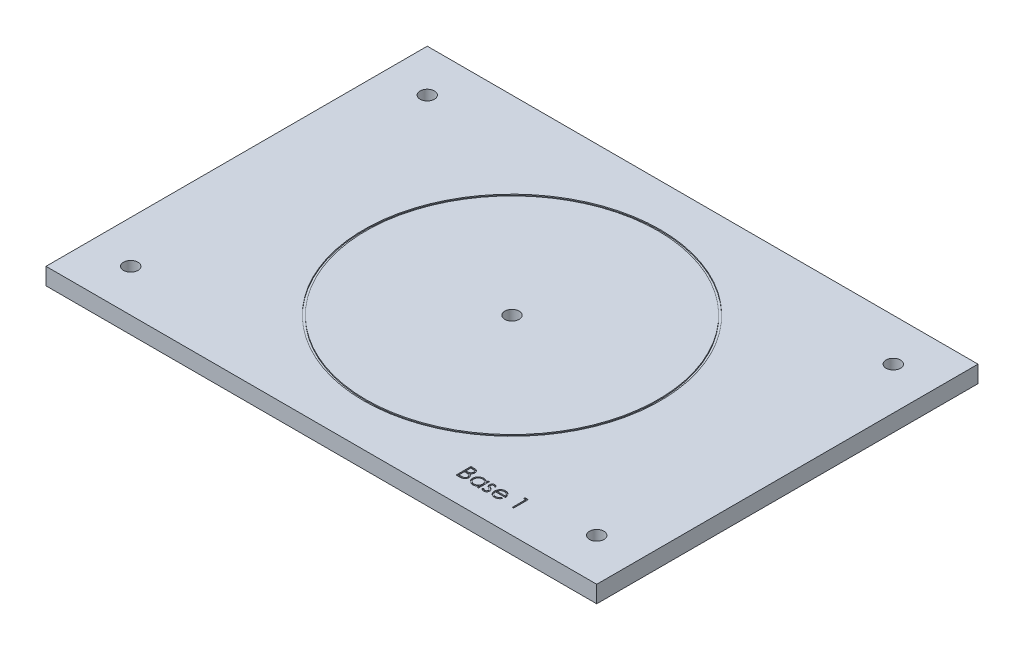
from build123d import *

# Parameters (mm, degrees)
CROQUIS1_W                       = 130
CROQUIS1_H                       = 90
SALIENTE_EXTRUIR1_DEPTH          = 2
TALADRO_DE_MARGEN_PARA_M31_D     = 3.4
TALADRO_DE_MARGEN_PARA_M31_DEPTH = 40
TALADRO_DE_MARGEN_PARA_M31_TIP   = 1.021463052
CORTAR_EXTRUIR1_DEPTH            = 0.25
CROQUIS5_R                       = 35
CROQUIS5_R_2                     = 34.5
CORTAR_EXTRUIR2_DEPTH            = 0.25
TALADRO_DE_MARGEN_PARA_M32_D     = 3.4


with BuildPart() as part:
    # Croquis1 → Saliente-Extruir1 (new, symmetric)
    with BuildSketch(Plane(origin=(0, 0, 0), x_dir=(1, 0, 0), z_dir=(0, 1, 0))):
        Rectangle(CROQUIS1_W, CROQUIS1_H)
    extrude(amount=SALIENTE_EXTRUIR1_DEPTH, both=True)

    # Taladro de margen para M31
    with Locations(Plane(origin=(0, 2, 0), x_dir=(1, 0, 0), z_dir=(0, 1, 0))):
        with Locations((-55, 35), (55, 35), (55, -35), (-55, -35)):
            Hole(TALADRO_DE_MARGEN_PARA_M31_D / 2, depth=TALADRO_DE_MARGEN_PARA_M31_DEPTH)
            with Locations((0, 0, -(TALADRO_DE_MARGEN_PARA_M31_DEPTH + TALADRO_DE_MARGEN_PARA_M31_TIP / 2))):  # 118° drill point
                Cone(0, TALADRO_DE_MARGEN_PARA_M31_D / 2, TALADRO_DE_MARGEN_PARA_M31_TIP, mode=Mode.SUBTRACT)

    # Croquis4 → Cortar-Extruir1 (cut)
    with BuildSketch(Plane(origin=(0, 2, 0), x_dir=(1, 0, 0), z_dir=(0, 1, 0))):
        with BuildLine():
            Line((26.072765662, -35.764073187), (26.75565829, -35.764073187))
            add(Edge.make_bspline(
                [(26.75565829, -35.764073187), (26.789086768, -35.764248937), (26.853879479, -35.764589586), (26.94809892, -35.769872717), (27.036347731, -35.777076387), (27.118651503, -35.788506479), (27.194972206, -35.802298256), (27.265539843, -35.819000072), (27.330130015, -35.839026686), (27.407242752, -35.870872967), (27.495163413, -35.918196136), (27.590361805, -35.988124701), (27.671766045, -36.073657164), (27.741952362, -36.170139819), (27.797753482, -36.276275591), (27.838122779, -36.38953478), (27.863680654, -36.508456522), (27.866309088, -36.5900997), (27.867637457, -36.631360847)],
                knots=[0, 0, 0, 0, 1.001505555, 1.941167018, 2.826882275, 3.653841531, 4.429895133, 5.150066043, 5.825578002, 6.45369114, 7.647487171, 8.808567382, 9.977351308, 11.170798116, 12.373658725, 13.556498008, 14.765093433, 16, 16, 16, 16], degree=3))
            add(Edge.make_bspline(
                [(27.867637457, -36.631360847), (27.866544238, -36.670013403), (27.864395961, -36.74596932), (27.843853202, -36.857063429), (27.811692533, -36.962814648), (27.766987284, -37.062837034), (27.708885288, -37.154870647), (27.640026969, -37.239657913), (27.556950167, -37.31360897), (27.494706927, -37.354951872), (27.463090181, -37.375952194)],
                knots=[0, 0, 0, 0, 1.044552857, 2.05264487, 3.044412934, 4.028983338, 5.005914585, 5.980388656, 6.974128949, 8, 8, 8, 8], degree=3))
            add(Edge.make_bspline(
                [(27.463090181, -37.375952194), (27.502850609, -37.391217192), (27.578922156, -37.420422917), (27.683608169, -37.472058381), (27.773803014, -37.528220491), (27.85020016, -37.589552341), (27.915537814, -37.655661152), (27.972590756, -37.727516266), (28.02127213, -37.806055024), (28.062985054, -37.89045856), (28.09553381, -37.979865028), (28.119909714, -38.073435804), (28.133877163, -38.170835359), (28.135864805, -38.237120739), (28.136868226, -38.270583604)],
                knots=[0, 0, 0, 0, 1.27268992, 2.434971085, 3.483601985, 4.442670788, 5.356604649, 6.2567628, 7.179492994, 8.113709626, 9.066344395, 10.018646069, 10.999752585, 12, 12, 12, 12], degree=3))
            add(Edge.make_bspline(
                [(28.136868226, -38.270583604), (28.13589138, -38.304750476), (28.133969408, -38.371974754), (28.119789436, -38.470729889), (28.095780329, -38.565104835), (28.062709183, -38.655710018), (28.019546868, -38.742370152), (27.967018904, -38.825183416), (27.90438734, -38.903317747), (27.834324471, -38.97764137), (27.755062326, -39.044469157), (27.669546571, -39.103984864), (27.576700251, -39.152930926), (27.478048257, -39.194046948), (27.372483941, -39.225454146), (27.260481334, -39.24742672), (27.142137032, -39.262231757), (27.060927281, -39.263448962), (27.019280085, -39.264073187)],
                knots=[0, 0, 0, 0, 0.978564426, 1.925352924, 2.850884081, 3.763762016, 4.682927383, 5.618979971, 6.567305752, 7.547517671, 8.540179244, 9.531824382, 10.526200242, 11.540722885, 12.589160233, 13.674978461, 14.80764778, 16, 16, 16, 16], degree=3))
            Line((27.019280085, -39.264073187), (26.072765662, -39.264073187))
            Line((26.072765662, -39.264073187), (26.072765662, -35.764073187))
        make_face()
        with BuildLine():
            Line((26.386868226, -36.123047546), (26.386868226, -37.244842418))
            Line((26.386868226, -37.244842418), (26.597905886, -37.244842418))
            add(Edge.make_bspline(
                [(26.597905886, -37.244842418), (26.628754682, -37.244442495), (26.688360841, -37.243669762), (26.774680737, -37.241456245), (26.854805756, -37.235258202), (26.928597589, -37.22906194), (26.995940033, -37.218987352), (27.056683894, -37.206995229), (27.111782491, -37.194312324), (27.175322037, -37.172742837), (27.247394985, -37.140865162), (27.324228089, -37.091393326), (27.391962559, -37.032468973), (27.449159747, -36.964478011), (27.495971217, -36.889611825), (27.528484932, -36.809064944), (27.550532216, -36.724844812), (27.552523748, -36.66702656), (27.553534893, -36.637670944)],
                knots=[0, 0, 0, 0, 1.156816544, 2.235205308, 3.236616184, 4.169592532, 5.011045266, 5.787822928, 6.49130361, 7.128639758, 8.301311294, 9.436451833, 10.541879658, 11.654887649, 12.756523258, 13.837046038, 14.901820046, 16, 16, 16, 16], degree=3))
            add(Edge.make_bspline(
                [(27.553534893, -36.637670944), (27.553008713, -36.618245172), (27.551976553, -36.5801394), (27.54352325, -36.524590046), (27.529155676, -36.472346293), (27.510701382, -36.422692183), (27.484912694, -36.377180333), (27.45454923, -36.334237137), (27.41786354, -36.295325018), (27.376106227, -36.25895552), (27.328097605, -36.226710992), (27.273866313, -36.198470229), (27.212678636, -36.175729453), (27.145565781, -36.1558133), (27.071494693, -36.141825006), (26.99132014, -36.130171619), (26.904385421, -36.124238877), (26.844240318, -36.123453514), (26.813150277, -36.123047546)],
                knots=[0, 0, 0, 0, 0.91205012, 1.789085906, 2.630437955, 3.453916878, 4.269457761, 5.079663411, 5.91843418, 6.774407191, 7.675494373, 8.627863946, 9.638891023, 10.736472738, 11.911756761, 13.175263542, 14.539845004, 16, 16, 16, 16], degree=3))
            Line((26.813150277, -36.123047546), (26.386868226, -36.123047546))
        make_face(mode=Mode.SUBTRACT)
        with BuildLine():
            Line((26.386868226, -37.603816777), (26.386868226, -38.905098828))
            Line((26.386868226, -38.905098828), (26.834183931, -38.905098828))
            add(Edge.make_bspline(
                [(26.834183931, -38.905098828), (26.866202857, -38.904715081), (26.927915116, -38.903975458), (27.017016346, -38.901560904), (27.09959945, -38.896068628), (27.175287585, -38.887422778), (27.244898038, -38.878044329), (27.307595741, -38.865433048), (27.363888934, -38.850984088), (27.429163242, -38.828649915), (27.50266675, -38.793953445), (27.581877607, -38.741639218), (27.652303825, -38.67931591), (27.712109084, -38.607184996), (27.761122073, -38.528753669), (27.796777528, -38.445608319), (27.818768385, -38.359122792), (27.821430554, -38.300156079), (27.822765662, -38.270583604)],
                knots=[0, 0, 0, 0, 1.160039823, 2.235823828, 3.228722157, 4.157150951, 4.99529583, 5.772374946, 6.472645482, 7.099169577, 8.269452708, 9.405989375, 10.527446681, 11.663510218, 12.788923519, 13.866172445, 14.929861265, 16, 16, 16, 16], degree=3))
            add(Edge.make_bspline(
                [(27.822765662, -38.270583604), (27.822489558, -38.252090263), (27.821941802, -38.215401881), (27.813681188, -38.161486062), (27.801667318, -38.109260189), (27.786135884, -38.058582448), (27.763516417, -38.010369072), (27.737109872, -37.963666513), (27.70614847, -37.918413033), (27.657904304, -37.86120078), (27.58773232, -37.795283767), (27.488025544, -37.730746265), (27.374653246, -37.678698457), (27.292425753, -37.656598981), (27.249949156, -37.645182963)],
                knots=[0, 0, 0, 0, 0.723448775, 1.435228256, 2.130040452, 2.821711965, 3.505591119, 4.210454504, 4.921174351, 5.648778258, 7.137944449, 8.670945889, 10.280296675, 12, 12, 12, 12], degree=3))
            add(Edge.make_bspline(
                [(27.249949156, -37.645182963), (27.23292006, -37.641727879), (27.195997467, -37.634236544), (27.135789887, -37.626328841), (27.067054018, -37.619283781), (26.989631141, -37.614072623), (26.9034233, -37.60868608), (26.808246381, -37.606591258), (26.704489066, -37.604091998), (26.632496694, -37.603910864), (26.595101399, -37.603816777)],
                knots=[0, 0, 0, 0, 0.634451884, 1.375622551, 2.216452059, 3.157844607, 4.20941857, 5.370758133, 6.634282058, 8, 8, 8, 8], degree=3))
            Line((26.595101399, -37.603816777), (26.386868226, -37.603816777))
        make_face(mode=Mode.SUBTRACT)
        with BuildLine():
            Line((31.367637457, -36.706380879), (31.367637457, -39.264073187))
            Line((31.367637457, -39.264073187), (31.053534893, -39.264073187))
            Line((31.053534893, -39.264073187), (31.053534893, -38.821665335))
            add(Edge.make_bspline(
                [(31.053534893, -38.821665335), (31.018116102, -38.861704928), (30.948995887, -38.9398427), (30.833554769, -39.041924872), (30.711186591, -39.126303194), (30.58248527, -39.194453109), (30.447567026, -39.245645166), (30.306730939, -39.282031325), (30.159919558, -39.30542516), (30.059667203, -39.307761182), (30.008863418, -39.308944982)],
                knots=[0, 0, 0, 0, 1.074387032, 2.096679803, 3.090159297, 4.057316773, 5.018401886, 5.985159533, 6.978961417, 8, 8, 8, 8], degree=3))
            add(Edge.make_bspline(
                [(30.008863418, -39.308944982), (29.963695464, -39.30771861), (29.87462226, -39.305300149), (29.743593182, -39.286537846), (29.617500933, -39.256407224), (29.49622636, -39.214506335), (29.380554215, -39.158925513), (29.269494118, -39.092384265), (29.163621426, -39.013143435), (29.064549887, -38.922555406), (28.973317887, -38.824160419), (28.893256614, -38.719214872), (28.826503534, -38.608172568), (28.770683454, -38.492439415), (28.727687109, -38.371124495), (28.697713475, -38.244647327), (28.678973028, -38.113157454), (28.676555568, -38.02361793), (28.675329764, -37.978215815)],
                knots=[0, 0, 0, 0, 1.033919861, 2.038935746, 3.024066025, 3.998881131, 4.97069526, 5.957263378, 6.95902576, 7.993208707, 9.027059324, 10.027763471, 11.009749337, 11.988697705, 12.965288445, 13.950418724, 14.960734635, 16, 16, 16, 16], degree=3))
            add(Edge.make_bspline(
                [(28.675329764, -37.978215815), (28.676582736, -37.933752112), (28.679059793, -37.845849768), (28.697513013, -37.71657107), (28.728544021, -37.59205281), (28.772091869, -37.472695866), (28.827933824, -37.358355816), (28.895861911, -37.248951791), (28.975881036, -37.144182394), (29.068133443, -37.046511167), (29.168068213, -36.956290553), (29.274976944, -36.877881507), (29.386200225, -36.810164658), (29.503463235, -36.756511182), (29.62503034, -36.713102078), (29.751983786, -36.68306911), (29.883795365, -36.665371788), (29.973285857, -36.662809024), (30.018679123, -36.661509085)],
                knots=[0, 0, 0, 0, 1.020392517, 2.01726096, 2.990465484, 3.961182959, 4.928053699, 5.906110375, 6.912531644, 7.948652711, 8.985773172, 9.998621852, 10.987621588, 11.969261332, 12.953316658, 13.946091881, 14.958173133, 16, 16, 16, 16], degree=3))
            add(Edge.make_bspline(
                [(30.018679123, -36.661509085), (30.070878983, -36.662946836), (30.173240443, -36.665766199), (30.322968452, -36.689228926), (30.46461293, -36.728867393), (30.599267282, -36.782784891), (30.726447968, -36.854433621), (30.844950952, -36.944813582), (30.956016435, -37.053354769), (31.020396727, -37.136725213), (31.053534893, -37.179638091)],
                knots=[0, 0, 0, 0, 1.038897134, 2.037228247, 3.008116434, 3.962042015, 4.918381754, 5.904844433, 6.921570401, 8, 8, 8, 8], degree=3))
            Line((31.053534893, -37.179638091), (31.053534893, -36.706380879))
            Line((31.053534893, -36.706380879), (31.367637457, -36.706380879))
        make_face()
        with BuildLine():
            add(Edge.make_bspline(
                [(30.022885854, -36.975611649), (29.976971516, -36.977245286), (29.886343916, -36.980469827), (29.753299914, -37.005643323), (29.6259865, -37.047527917), (29.505040426, -37.104809818), (29.392372209, -37.176838555), (29.291678539, -37.263959938), (29.202135837, -37.363796952), (29.126827573, -37.475899063), (29.065437076, -37.596077154), (29.022270044, -37.721701592), (28.993800797, -37.850506569), (28.990892276, -37.937869255), (28.989432329, -37.981721424)],
                knots=[0, 0, 0, 0, 1.031046209, 2.035121221, 3.029706178, 4.034933723, 5.034054252, 6.02443088, 7.017295772, 8.038157696, 9.050218397, 10.03989886, 11.016116709, 12, 12, 12, 12], degree=3))
            add(Edge.make_bspline(
                [(28.989432329, -37.981721424), (28.991297222, -38.025311531), (28.995019699, -38.112320887), (29.021770393, -38.241301464), (29.066650267, -38.366955506), (29.127892329, -38.4882165), (29.204578954, -38.6008006), (29.293467607, -38.702540723), (29.395417888, -38.790030311), (29.508345395, -38.863267884), (29.628953365, -38.922430405), (29.755787297, -38.963596045), (29.886462935, -38.990173826), (29.975315269, -38.993278302), (30.020081367, -38.994842418)],
                knots=[0, 0, 0, 0, 0.979072187, 1.954306742, 2.945804271, 3.96968567, 4.997920485, 5.998718438, 6.996577872, 8.005894225, 9.015743152, 10.005417472, 10.995077863, 12, 12, 12, 12], degree=3))
            add(Edge.make_bspline(
                [(30.020081367, -38.994842418), (30.06552787, -38.993182454), (30.155916456, -38.98988095), (30.289355164, -38.964599685), (30.418850127, -38.922830887), (30.542637355, -38.86493176), (30.657953487, -38.793174404), (30.761451364, -38.709167313), (30.848967333, -38.611464129), (30.923159942, -38.504087676), (30.981335359, -38.386375679), (31.023711418, -38.261041489), (31.048765324, -38.128080741), (31.051923053, -38.037216814), (31.053534893, -37.990836008)],
                knots=[0, 0, 0, 0, 1.01762866, 2.023962475, 3.030623092, 4.058876274, 5.077231937, 6.066672613, 7.034107872, 8.005628644, 8.981990164, 9.965428785, 10.961468474, 12, 12, 12, 12], degree=3))
            add(Edge.make_bspline(
                [(31.053534893, -37.990836008), (31.052575236, -37.955498177), (31.050686329, -37.885942144), (31.036255759, -37.783814626), (31.013300833, -37.6860809), (30.980954663, -37.592638211), (30.938463379, -37.504003196), (30.887215613, -37.419539435), (30.826310163, -37.339686224), (30.756727467, -37.265543153), (30.680562264, -37.197916691), (30.599967724, -37.13755245), (30.513988977, -37.087963677), (30.42407194, -37.046922406), (30.330060605, -37.014263256), (30.231189985, -36.992475562), (30.128510999, -36.977515241), (30.058464943, -36.97625286), (30.022885854, -36.975611649)],
                knots=[0, 0, 0, 0, 1.050140795, 2.067009409, 3.05949893, 4.030605086, 5.00011959, 5.97591094, 6.962425594, 7.979863591, 8.993523472, 9.986985069, 10.967611495, 11.937549037, 12.921786183, 13.919465291, 14.943216303, 16, 16, 16, 16], degree=3))
        make_face(mode=Mode.SUBTRACT)
        with BuildLine():
            Line((33.297124636, -37.025391296), (33.083983611, -37.244842418))
            add(Edge.make_bspline(
                [(33.083983611, -37.244842418), (33.065593107, -37.223529272), (33.030138381, -37.182440034), (32.9739069, -37.127502968), (32.917883297, -37.081366029), (32.862834483, -37.04241377), (32.807376214, -37.012964624), (32.752159296, -36.991469762), (32.697126557, -36.978167956), (32.660340522, -36.976453517), (32.64227688, -36.975611649)],
                knots=[0, 0, 0, 0, 1.26578478, 2.440284043, 3.530471711, 4.527705817, 5.468200915, 6.346673037, 7.188140097, 8, 8, 8, 8], degree=3))
            add(Edge.make_bspline(
                [(32.64227688, -36.975611649), (32.62013749, -36.976686522), (32.576570304, -36.97880172), (32.514144486, -36.99991515), (32.456193861, -37.032323888), (32.406036881, -37.078292472), (32.363549201, -37.131056741), (32.33253552, -37.190053066), (32.313569536, -37.253501109), (32.311164804, -37.297530967), (32.309945149, -37.31986245)],
                knots=[0, 0, 0, 0, 0.99966794, 1.967205029, 2.953328237, 3.988086729, 5.028030931, 6.008226631, 6.989793394, 8, 8, 8, 8], degree=3))
            add(Edge.make_bspline(
                [(32.309945149, -37.31986245), (32.311055961, -37.340074494), (32.313274455, -37.380441605), (32.330521134, -37.439989639), (32.357987206, -37.498046677), (32.3836574, -37.533609583), (32.396884252, -37.551933764)],
                knots=[0, 0, 0, 0, 0.960159726, 1.917612774, 2.927026955, 4, 4, 4, 4], degree=3))
            add(Edge.make_bspline(
                [(32.396884252, -37.551933764), (32.404847745, -37.561718348), (32.421797038, -37.582543603), (32.453605553, -37.611447456), (32.489628056, -37.643389707), (32.532947994, -37.675326544), (32.581699022, -37.708958269), (32.636938306, -37.742960402), (32.696912811, -37.779924827), (32.739850118, -37.803369263), (32.762168707, -37.815555559)],
                knots=[0, 0, 0, 0, 0.66740084, 1.420478572, 2.27185888, 3.217733974, 4.268547843, 5.408967954, 6.65319498, 8, 8, 8, 8], degree=3))
            add(Edge.make_bspline(
                [(32.762168707, -37.815555559), (32.789382284, -37.830800462), (32.841949954, -37.860248594), (32.916642721, -37.905958298), (32.984429762, -37.951389722), (33.04588543, -37.996056996), (33.099827239, -38.041209863), (33.147891791, -38.08511762), (33.188880235, -38.129106929), (33.211834162, -38.159840042), (33.222805726, -38.174529918)],
                knots=[0, 0, 0, 0, 1.27191281, 2.456916733, 3.569705269, 4.599008579, 5.553216877, 6.436649441, 7.252746552, 8, 8, 8, 8], degree=3))
            add(Edge.make_bspline(
                [(33.222805726, -38.174529918), (33.241016253, -38.204196006), (33.277258583, -38.263237027), (33.315316849, -38.360455454), (33.337377124, -38.463565957), (33.340439344, -38.534098177), (33.341996431, -38.56996261)],
                knots=[0, 0, 0, 0, 0.995354457, 1.980940102, 2.973342416, 4, 4, 4, 4], degree=3))
            add(Edge.make_bspline(
                [(33.341996431, -38.56996261), (33.341276897, -38.595231756), (33.339858977, -38.64502737), (33.33000091, -38.718362199), (33.313045934, -38.788496757), (33.28995218, -38.856192041), (33.258767807, -38.920150981), (33.22222001, -38.98198723), (33.178345098, -39.040363161), (33.128253723, -39.095202121), (33.073408229, -39.145287868), (33.01490209, -39.189311822), (32.95266326, -39.22588616), (32.887136458, -39.256151505), (32.818172804, -39.280219763), (32.745761515, -39.296882294), (32.67013276, -39.306855055), (32.618702952, -39.308239531), (32.592497232, -39.308944982)],
                knots=[0, 0, 0, 0, 1.032770009, 2.035186124, 3.017557409, 3.978232242, 4.952395191, 5.920591857, 6.910227898, 7.931268572, 8.952309245, 9.941945286, 10.918353717, 11.897095711, 12.887975737, 13.898235213, 14.929059601, 16, 16, 16, 16], degree=3))
            add(Edge.make_bspline(
                [(32.592497232, -39.308944982), (32.557130057, -39.307952282), (32.48688713, -39.305980674), (32.382997411, -39.287474613), (32.281476652, -39.258679219), (32.183093112, -39.218963285), (32.090046998, -39.168812572), (32.004916073, -39.108750179), (31.927404611, -39.040760181), (31.883286337, -38.988647271), (31.8612272, -38.962590815)],
                knots=[0, 0, 0, 0, 1.013940152, 2.01379169, 3.017749504, 4.037548394, 5.051665909, 6.043208538, 7.021604269, 8, 8, 8, 8], degree=3))
            Line((31.8612272, -38.962590815), (32.069460373, -38.725611649))
            add(Edge.make_bspline(
                [(32.069460373, -38.725611649), (32.089232786, -38.746966413), (32.127564599, -38.788365853), (32.188865815, -38.843490194), (32.251245217, -38.889691465), (32.314079903, -38.92833488), (32.378299997, -38.958110283), (32.443545612, -38.979028877), (32.509684036, -38.992473069), (32.554106172, -38.994051351), (32.576371431, -38.994842418)],
                knots=[0, 0, 0, 0, 1.179806542, 2.287233372, 3.337373186, 4.324005949, 5.273901747, 6.200048787, 7.097828587, 8, 8, 8, 8], degree=3))
            add(Edge.make_bspline(
                [(32.576371431, -38.994842418), (32.606689357, -38.993471593), (32.665925499, -38.990793231), (32.750769257, -38.966476139), (32.829107884, -38.928346187), (32.897131229, -38.874261489), (32.95503339, -38.811305917), (32.996961565, -38.740391797), (33.02323774, -38.663600341), (33.026323739, -38.610368038), (33.027893867, -38.583283924)],
                knots=[0, 0, 0, 0, 1.072336372, 2.095165389, 3.102688358, 4.141489647, 5.156069229, 6.117746104, 7.042326257, 8, 8, 8, 8], degree=3))
            add(Edge.make_bspline(
                [(33.027893867, -38.583283924), (33.026807573, -38.560974306), (33.02466283, -38.51692695), (33.007819558, -38.453176609), (32.981206706, -38.392707328), (32.955002057, -38.357317681), (32.941655886, -38.33929354)],
                knots=[0, 0, 0, 0, 1.013901739, 2.00181326, 2.98231254, 4, 4, 4, 4], degree=3))
            add(Edge.make_bspline(
                [(32.941655886, -38.33929354), (32.933633492, -38.330258178), (32.916157819, -38.310575895), (32.884102578, -38.282150817), (32.845720716, -38.251512717), (32.800580553, -38.219181129), (32.748591091, -38.185582523), (32.689541616, -38.150893171), (32.624241063, -38.113465445), (32.578070432, -38.08864579), (32.553935534, -38.075671745)],
                knots=[0, 0, 0, 0, 0.615000592, 1.339693406, 2.178160186, 3.116406724, 4.166410947, 5.330106347, 6.604359322, 8, 8, 8, 8], degree=3))
            add(Edge.make_bspline(
                [(32.553935534, -38.075671745), (32.527888894, -38.061132613), (32.477376146, -38.032936597), (32.405828855, -37.989020517), (32.341281501, -37.944353242), (32.282180926, -37.901440403), (32.230019921, -37.858019459), (32.185003972, -37.814042207), (32.145360757, -37.771282221), (32.123413345, -37.740984925), (32.112929925, -37.726513091)],
                knots=[0, 0, 0, 0, 1.262093308, 2.447601706, 3.550203992, 4.582594899, 5.537233252, 6.418365656, 7.244515135, 8, 8, 8, 8], degree=3))
            add(Edge.make_bspline(
                [(32.112929925, -37.726513091), (32.094799325, -37.697367476), (32.05853179, -37.639066061), (32.023316599, -37.541755584), (31.99911057, -37.439310527), (31.99694818, -37.368623672), (31.995842585, -37.332482642)],
                knots=[0, 0, 0, 0, 0.985009483, 1.970363186, 2.962279964, 4, 4, 4, 4], degree=3))
            add(Edge.make_bspline(
                [(31.995842585, -37.332482642), (31.99637678, -37.308857244), (31.997422276, -37.262618993), (32.005766328, -37.194680173), (32.020958039, -37.130132019), (32.040012962, -37.068005156), (32.066495966, -37.009503062), (32.098141871, -36.953845591), (32.135329296, -36.901109673), (32.178172587, -36.852106541), (32.225279232, -36.807597215), (32.276174002, -36.768798587), (32.329712259, -36.735692232), (32.386120678, -36.707927071), (32.445941151, -36.686925689), (32.508755537, -36.672468304), (32.574436692, -36.662813101), (32.619337818, -36.661950017), (32.64227688, -36.661509085)],
                knots=[0, 0, 0, 0, 1.087655834, 2.128696564, 3.144119009, 4.137814668, 5.115653402, 6.093965665, 7.082169637, 8.081268856, 9.086088321, 10.061021666, 11.022561449, 11.980240094, 12.950172527, 13.934149372, 14.944599409, 16, 16, 16, 16], degree=3))
            add(Edge.make_bspline(
                [(32.64227688, -36.661509085), (32.669468943, -36.662613425), (32.724363165, -36.664842823), (32.806717791, -36.682548514), (32.888951133, -36.711681618), (32.971274483, -36.751917851), (33.053084773, -36.803984727), (33.135101629, -36.866914026), (33.21830966, -36.940291741), (33.270265973, -36.996390966), (33.297124636, -37.025391296)],
                knots=[0, 0, 0, 0, 0.845714091, 1.707292901, 2.609013841, 3.555613372, 4.552488639, 5.621697636, 6.770543573, 8, 8, 8, 8], degree=3))
        make_face()
        with BuildLine():
            Line((36.069360213, -38.456380879), (36.348406688, -38.602915335))
            add(Edge.make_bspline(
                [(36.348406688, -38.602915335), (36.326170092, -38.642358666), (36.282906484, -38.719099769), (36.208505736, -38.824531629), (36.130513663, -38.919379345), (36.045409695, -39.001108999), (35.955740016, -39.072360384), (35.861007362, -39.134698209), (35.760718544, -39.187816729), (35.654868819, -39.232569257), (35.542569268, -39.266978751), (35.423547752, -39.291282972), (35.297576256, -39.306306241), (35.211230076, -39.308051382), (35.167016463, -39.308944982)],
                knots=[0, 0, 0, 0, 1.120438281, 2.179929193, 3.190490725, 4.156257408, 5.095198341, 6.022838206, 6.959905092, 7.901321166, 8.864066838, 9.862729781, 10.905609505, 12, 12, 12, 12], degree=3))
            add(Edge.make_bspline(
                [(35.167016463, -39.308944982), (35.117874486, -39.307797807), (35.022012724, -39.30556), (34.882472977, -39.286267535), (34.751093558, -39.254795177), (34.627881855, -39.210829635), (34.513139603, -39.153402311), (34.406638748, -39.083442829), (34.307819222, -39.001310575), (34.219795013, -38.906294131), (34.14055113, -38.804612174), (34.07062531, -38.698656289), (34.012167879, -38.588693065), (33.964615269, -38.475422541), (33.926210404, -38.359558647), (33.8994437, -38.24004718), (33.884013952, -38.117211596), (33.881649507, -38.03411426), (33.88045797, -37.992238251)],
                knots=[0, 0, 0, 0, 1.145258523, 2.234067595, 3.276747158, 4.290159414, 5.277019952, 6.260822364, 7.254936242, 8.264827045, 9.274100331, 10.257902744, 11.220704747, 12.172965371, 13.118907548, 14.062713208, 15.023725156, 16, 16, 16, 16], degree=3))
            add(Edge.make_bspline(
                [(33.88045797, -37.992238251), (33.881517111, -37.952943421), (33.883616189, -37.875066256), (33.896846977, -37.759800712), (33.92029527, -37.647772259), (33.952471594, -37.538887811), (33.99402284, -37.433329677), (34.044855059, -37.331033613), (34.105047437, -37.232108474), (34.151520111, -37.16970534), (34.174929123, -37.138271905)],
                knots=[0, 0, 0, 0, 1.024358464, 2.0301432, 3.019427413, 4.004406732, 4.986367066, 5.972626655, 6.978780325, 8, 8, 8, 8], degree=3))
            add(Edge.make_bspline(
                [(34.174929123, -37.138271905), (34.206636806, -37.100403035), (34.269047753, -37.025864885), (34.374604108, -36.927926559), (34.488904305, -36.845882784), (34.610515931, -36.777875647), (34.740852405, -36.726202), (34.878161696, -36.687694418), (35.024007282, -36.666116407), (35.123712503, -36.663068574), (35.174728803, -36.661509085)],
                knots=[0, 0, 0, 0, 1.030682036, 2.02871468, 2.997146059, 3.962720338, 4.930598197, 5.918074684, 6.934738563, 8, 8, 8, 8], degree=3))
            add(Edge.make_bspline(
                [(35.174728803, -36.661509085), (35.227176408, -36.662863133), (35.330066654, -36.665519469), (35.480098775, -36.690145802), (35.622059492, -36.729198357), (35.755891996, -36.784352147), (35.881609857, -36.855511699), (35.998395906, -36.94365354), (36.108247419, -37.046071628), (36.172155998, -37.124834837), (36.20467672, -37.164914533)],
                knots=[0, 0, 0, 0, 1.056321875, 2.072262726, 3.055038591, 4.01806755, 4.982017516, 5.957941055, 6.960871419, 8, 8, 8, 8], degree=3))
            add(Edge.make_bspline(
                [(36.20467672, -37.164914533), (36.226803658, -37.195118115), (36.270910251, -37.255324233), (36.326157351, -37.35349539), (36.374114746, -37.456205985), (36.412447707, -37.565116282), (36.443487208, -37.678935862), (36.465944027, -37.798478407), (36.479113646, -37.923708318), (36.481702343, -38.009034874), (36.483022072, -38.052534726)],
                knots=[0, 0, 0, 0, 0.94817472, 1.890038105, 2.849395472, 3.817997239, 4.812318967, 5.836947057, 6.897266129, 8, 8, 8, 8], degree=3))
            Line((36.483022072, -38.052534726), (34.194560534, -38.052534726))
            add(Edge.make_bspline(
                [(34.194560534, -38.052534726), (34.19610014, -38.08623519), (34.199127714, -38.152505794), (34.213242857, -38.249476577), (34.235491631, -38.341849919), (34.266760694, -38.428932961), (34.304627539, -38.511863088), (34.351013256, -38.590025125), (34.40635281, -38.663063055), (34.468078509, -38.731630193), (34.536785604, -38.792690954), (34.609068352, -38.84734273), (34.685961917, -38.893148327), (34.76686, -38.930328217), (34.851631785, -38.959434533), (34.94030398, -38.979302354), (35.032702097, -38.99260946), (35.095687831, -38.994089126), (35.127753643, -38.994842418)],
                knots=[0, 0, 0, 0, 1.094153842, 2.151609401, 3.174256925, 4.172055639, 5.149267565, 6.128595816, 7.11444997, 8.118368179, 9.117203808, 10.09244225, 11.054858984, 12.015122123, 12.976791628, 13.957293641, 14.960065497, 16, 16, 16, 16], degree=3))
            add(Edge.make_bspline(
                [(35.127753643, -38.994842418), (35.15910479, -38.994234361), (35.221311481, -38.99302786), (35.313952339, -38.981295949), (35.405091866, -38.962325674), (35.494352849, -38.936435684), (35.579923695, -38.904858831), (35.659169245, -38.866755974), (35.732049461, -38.824606227), (35.800166427, -38.776396552), (35.866237421, -38.717388365), (35.931779907, -38.643752644), (36.002056561, -38.556665116), (36.046046153, -38.49111945), (36.069360213, -38.456380879)],
                knots=[0, 0, 0, 0, 0.99110716, 1.966546729, 2.947904876, 3.932708344, 4.903319531, 5.828989031, 6.710028674, 7.56322171, 8.463672341, 9.504779593, 10.677557249, 12, 12, 12, 12], degree=3))
        make_face()
        with BuildLine():
            add(Edge.make_bspline(
                [(36.168919508, -37.738432161), (36.157422884, -37.696769288), (36.135295582, -37.616581667), (36.089059218, -37.505540777), (36.036987677, -37.406852876), (35.975365946, -37.321273243), (35.90554722, -37.24526973), (35.824902037, -37.178851144), (35.734466144, -37.119433693), (35.634707003, -37.069281194), (35.529065218, -37.026591335), (35.418459026, -36.997966219), (35.305601238, -36.978356677), (35.229266952, -36.976530569), (35.190854604, -36.975611649)],
                knots=[0, 0, 0, 0, 1.154881502, 2.222775134, 3.210006277, 4.132804581, 5.035138423, 5.962687519, 6.919655026, 7.923214229, 8.944639381, 9.960483929, 10.97369054, 12, 12, 12, 12], degree=3))
            add(Edge.make_bspline(
                [(35.190854604, -36.975611649), (35.159505166, -36.97622332), (35.097533917, -36.977432466), (35.006232848, -36.988902596), (34.91855315, -37.00786244), (34.833847862, -37.033827397), (34.753226994, -37.068436), (34.675032225, -37.109019226), (34.601251829, -37.15856081), (34.555110534, -37.196319665), (34.531800117, -37.215395302)],
                knots=[0, 0, 0, 0, 1.04873581, 2.073130211, 3.073294108, 4.04793562, 5.032784715, 6.005352987, 6.992311501, 8, 8, 8, 8], degree=3))
            add(Edge.make_bspline(
                [(34.531800117, -37.215395302), (34.515106835, -37.230489618), (34.481323701, -37.261036834), (34.436183179, -37.313666041), (34.392962707, -37.370417603), (34.353629054, -37.433462727), (34.317551467, -37.502083506), (34.28379149, -37.575701142), (34.253405078, -37.654874272), (34.236308968, -37.710046711), (34.227513258, -37.738432161)],
                knots=[0, 0, 0, 0, 0.879870761, 1.780643979, 2.707998968, 3.669668524, 4.684282772, 5.740141944, 6.837334558, 8, 8, 8, 8], degree=3))
            Line((34.227513258, -37.738432161), (36.168919508, -37.738432161))
        make_face(mode=Mode.SUBTRACT)
        Polygon((38.976912297, -35.764073187), (39.624047713, -35.764073187), (39.624047713, -39.264073187), (39.309945149, -39.264073187), (39.309945149, -36.123047546), (38.771483611, -36.123047546), align=None)
    extrude(amount=-CORTAR_EXTRUIR1_DEPTH, mode=Mode.SUBTRACT)

    # Croquis5 → Cortar-Extruir2 (cut)
    with BuildSketch(Plane(origin=(0, 2, 0), x_dir=(1, 0, 0), z_dir=(0, 1, 0))):
        with Locations(Location((0, 0, 0), (0, 0, 270))):
            Circle(CROQUIS5_R)
        with Locations(Location((0, 0, 0), (0, 0, 270))):
            Circle(CROQUIS5_R_2, mode=Mode.SUBTRACT)
    extrude(amount=-CORTAR_EXTRUIR2_DEPTH, mode=Mode.SUBTRACT)

    # Taladro de margen para M32 (through all)
    with Locations(Plane(origin=(0, 2, 0), x_dir=(1, 0, 0), z_dir=(0, 1, 0))):
        with Locations((0, 0)):
            Hole(TALADRO_DE_MARGEN_PARA_M32_D / 2)


solid = part.part
